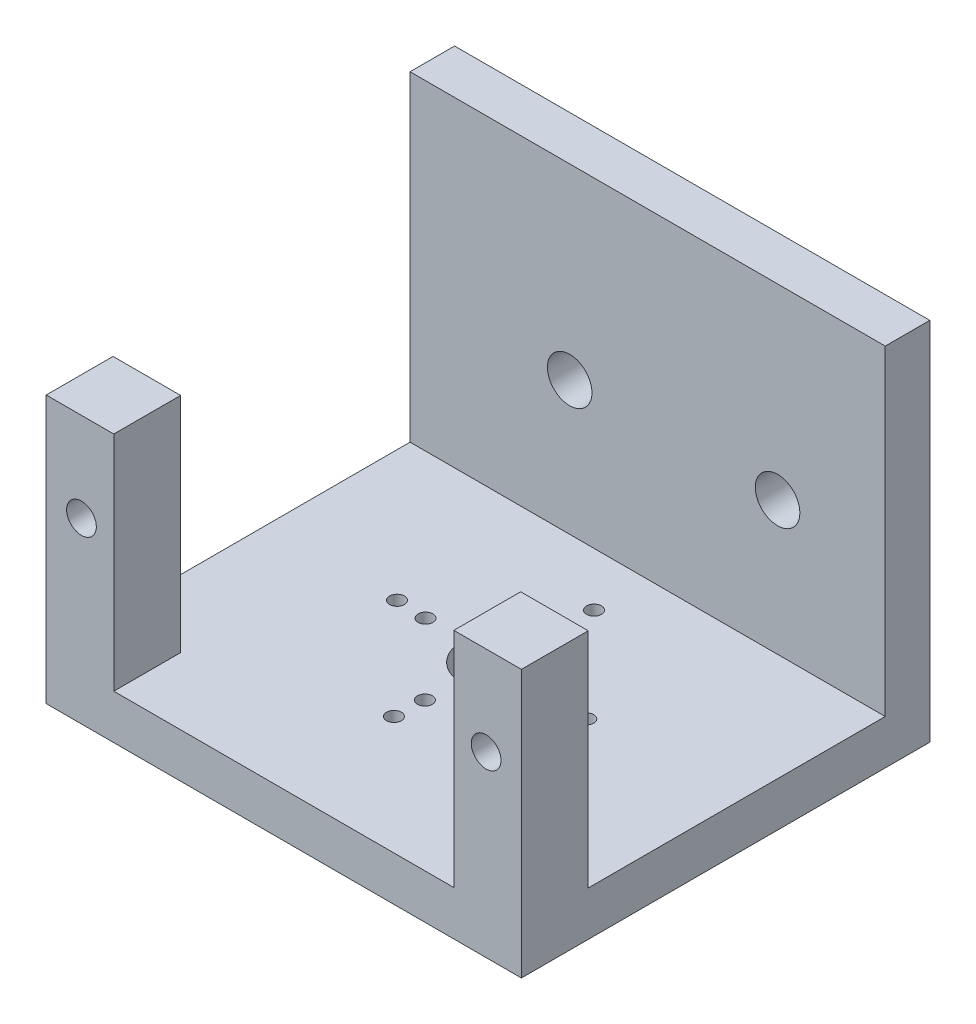
from build123d import *

# Parameters (mm, degrees)
SKETCH1_W           = 100
SKETCH1_H           = 100
BOSS_EXTRUDE1_DEPTH = 3
CUT_EXTRUDE1_DEPTH  = 10
SKETCH3_W           = 43.709135707
SKETCH3_H           = 24.60304044
BOSS_EXTRUDE2_DEPTH = 3
SKETCH4_W           = 43.709135707
SKETCH4_H           = 3
BOSS_EXTRUDE3_DEPTH = 1.730043545
BOSS_EXTRUDE4_START = -4.5
SKETCH6_W           = 4.55
SKETCH6_H           = 15
BOSS_EXTRUDE4_DEPTH = 4.5
SKETCH7_W           = 27.5
SKETCH7_H           = 24.60304044
CUT_EXTRUDE2_DEPTH  = 11.709135707
SKETCH9_R           = 1
CUT_EXTRUDE3_DEPTH  = 10
SKETCH10_R          = 0.5
CUT_EXTRUDE4_DEPTH  = 10
SKETCH12_R          = 2.35
CUT_EXTRUDE6_DEPTH  = 10
SKETCH11_R          = 1.5
CUT_EXTRUDE7_DEPTH  = 10
SKETCH13_R          = 1.5
CUT_EXTRUDE8_DEPTH  = 10


with BuildPart() as part:
    # Sketch1 → Boss-Extrude1 (new body)
    with BuildSketch(Plane(origin=(0, 0, 0), x_dir=(1, 0, 0), z_dir=(0, 1, 0))):
        with Locations((50, 50)):
            Rectangle(SKETCH1_W, SKETCH1_H)
    extrude(amount=BOSS_EXTRUDE1_DEPTH)

    # Sketch2 → Cut-Extrude1 (cut)
    with BuildSketch(Plane.XZ):
        Polygon((100, -100), (0, -100), (0, -25.769956455), (0, 0), (22.949850764, 0), (22.949850764, -25.769956455), (66.658986471, -25.769956455), (66.658986471, 0), (100, 0), (100, -25.769956455), align=None)
    extrude(amount=-CUT_EXTRUDE1_DEPTH, mode=Mode.SUBTRACT)

    # Sketch3 → Boss-Extrude2 (add)
    with BuildSketch(Plane(origin=(0, 0, -25.769956455), x_dir=(-1, 0, 0), z_dir=(0, 0, -1))):
        with Locations((-44.804418618, 12.30152022)):
            Rectangle(SKETCH3_W, SKETCH3_H)
    extrude(amount=-BOSS_EXTRUDE2_DEPTH)

    # Sketch4 → Boss-Extrude3 (add)
    with BuildSketch(Plane.XY):
        with Locations((44.804418618, 1.5)):
            Rectangle(SKETCH4_W, SKETCH4_H)
    extrude(amount=BOSS_EXTRUDE3_DEPTH)

    # Sketch6 → Boss-Extrude4 (add)
    with BuildSketch(Plane.XY.offset(1.730043545).offset(BOSS_EXTRUDE4_START)):
        with Locations((64.383986471, 10.5)):
            Rectangle(SKETCH6_W, SKETCH6_H)
        with Locations((36.933986471, 10.5)):
            Rectangle(SKETCH6_W, SKETCH6_H)
    extrude(amount=BOSS_EXTRUDE4_DEPTH)

    # Sketch7 → Cut-Extrude2 (cut)
    with BuildSketch(Plane.ZY.offset(-22.949850764)):
        with Locations((-12.019956455, 12.30152022)):
            Rectangle(SKETCH7_W, SKETCH7_H)
    extrude(amount=-CUT_EXTRUDE2_DEPTH, mode=Mode.SUBTRACT)

    # Sketch9 → Cut-Extrude3 (cut)
    with BuildSketch(Plane(origin=(0, 0, -2.769956455), x_dir=(-1, 0, 0), z_dir=(0, 0, -1))):
        with Locations((-37.033986471, 12)):
            Circle(SKETCH9_R)
        with Locations((-64.283986471, 12)):
            Circle(SKETCH9_R)
    extrude(amount=-CUT_EXTRUDE3_DEPTH, mode=Mode.SUBTRACT)

    # Sketch10 → Cut-Extrude4 (cut)
    with BuildSketch(Plane.XZ):
        with Locations(Location((50.117281123, -6.230612141, 0), (0, 0, 270))):
            Circle(SKETCH10_R)
        with Locations(Location((50.199353868, -8.228927447, 0), (0, 0, 270))):
            Circle(SKETCH10_R)
        with Locations(Location((54.734456973, -12.646544433, 0), (0, 0, 270))):
            Circle(SKETCH10_R)
        with Locations(Location((45.442290797, -13.028182696, 0), (0, 0, 270))):
            Circle(SKETCH10_R)
        with Locations(Location((50.566629401, -17.171388444, 0), (0, 0, 270))):
            Circle(SKETCH10_R)
        with Locations(Location((50.648702146, -19.169703751, 0), (0, 0, 270))):
            Circle(SKETCH10_R)
        with Locations(Location((56.732772279, -12.564471688, 0), (0, 0, 270))):
            Circle(SKETCH10_R)
        with Locations(Location((43.443975491, -13.110255441, 0), (0, 0, 270))):
            Circle(SKETCH10_R)
    extrude(amount=-CUT_EXTRUDE4_DEPTH, mode=Mode.SUBTRACT)

    # Sketch12 → Cut-Extrude6 (cut)
    with BuildSketch(Plane.XZ):
        with Locations(Location((50.388121181, -12.825052652, 0), (0, 0, 270))):
            Circle(SKETCH12_R)
    extrude(amount=-CUT_EXTRUDE6_DEPTH, mode=Mode.SUBTRACT)

    # Sketch11 → Cut-Extrude7 (cut)
    with BuildSketch(Plane(origin=(0, 0, -25.769956455), x_dir=(-1, 0, 0), z_dir=(0, 0, -1))):
        with Locations((-45.408986471, 12)):
            Circle(SKETCH11_R)
    extrude(amount=-CUT_EXTRUDE7_DEPTH, mode=Mode.SUBTRACT)

    # Sketch13 → Cut-Extrude8 (cut)
    with BuildSketch(Plane(origin=(0, 0, -25.769956455), x_dir=(-1, 0, 0), z_dir=(0, 0, -1))):
        with Locations((-59.408986471, 12)):
            Circle(SKETCH13_R)
    extrude(amount=-CUT_EXTRUDE8_DEPTH, mode=Mode.SUBTRACT)


solid = part.part
